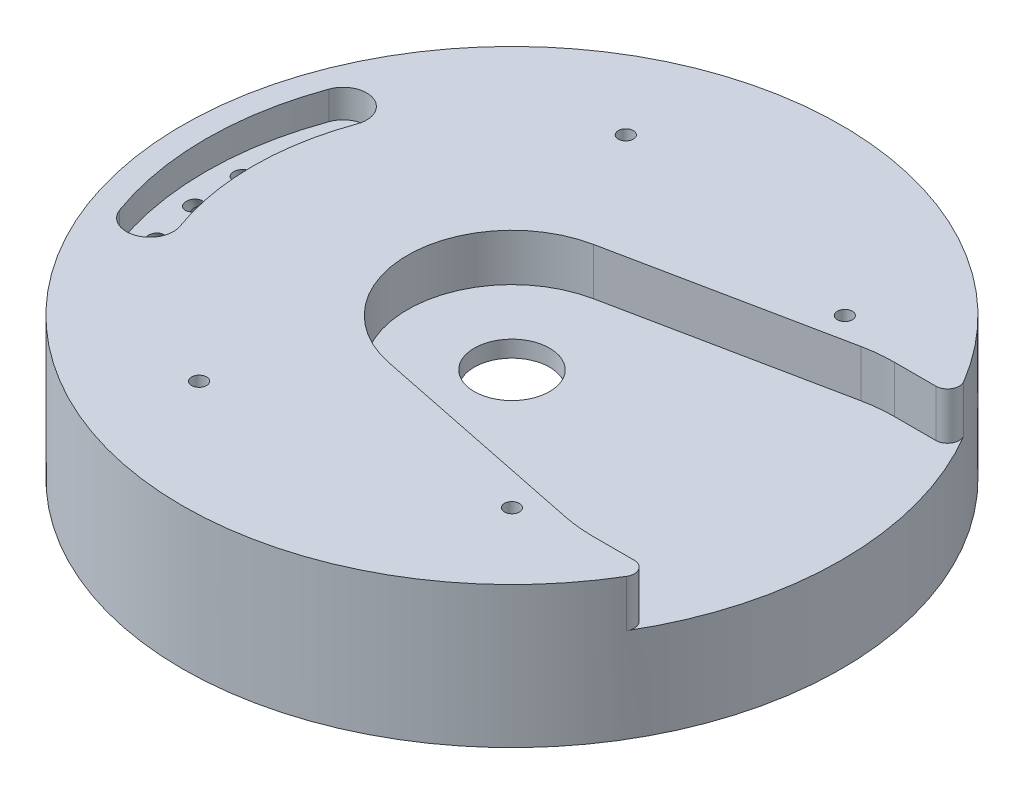
from build123d import *

# Parameters (mm, degrees)
SKETCH1_R                       = 10.16
GEAR_SLOT_DEPTH                 = 12.7
CIRPATTERN1_COUNT               = 2
CIRPATTERN1_ANGLE               = 10
CIRPATTERN1_THE_OTHER_WAY_COUNT = 2
CIRPATTERN1_THE_OTHER_WAY_ANGLE = 10
GAS_MANIFOLD_DEPTH              = 7.62
FILLET1_R                       = 3.175
TAP_DRILL_FOR_10_32_TAP1_D      = 4.0386
TAP_DRILL_FOR_10_32_TAP1_DEPTH  = 17.836682152
TAP_DRILL_FOR_10_32_TAP1_TIP    = 1.213317848


with BuildPart() as part:
    # Sketch9 → Revolve1 (revolve)
    with BuildSketch(Plane.XY, mode=Mode.PRIVATE) as revolve1_sk:
        Polygon((-10.16, 10.16), (-10.16, 27.305), (-88.9, 27.305), (-88.9, -10.795), (-80.645, -10.795), (-80.645, 10.795), (-69.85, 10.795), (-69.85, 5.08), (-58.42, 5.08), (-58.42, 6.35), (-45.72, 6.35), (-45.72, 7.62), (-33.02, 7.62), (-33.02, 10.16), align=None)
    revolve(revolve1_sk.sketch.rotate(Axis((0, 18.1216542, 0), (0, -1, 0)), 270), axis=Axis((0, 18.1216542, 0), (0, -1, 0)))

    # Sketch1 → Gear Slot (cut)
    with BuildSketch(Plane(origin=(0, 27.305, 0), x_dir=(1, 0, 0), z_dir=(0, 1, 0))):
        with BuildLine():
            Line((62.5, -40.675), (79.049063087, -40.675))
            ThreePointArc((79.049063087, -40.675), (88.9, 0), (79.049063087, 40.675))
            Line((79.049063087, 40.675), (62.5, 40.675))
            ThreePointArc((62.5, 40.675), (58.41179797, 40.469028023), (54.365, 39.853198115))
            Line((54.365, 39.853198115), (-5.635, 27.605749401))
            ThreePointArc((-5.635, 27.605749401), (-28.175, 0), (-5.635, -27.605749401))
            Line((-5.635, -27.605749401), (54.365, -39.853198115))
            ThreePointArc((54.365, -39.853198115), (58.41179797, -40.469028023), (62.5, -40.675))
        make_face()
        with Locations(Location((0, 0, 0), (0, 0, 270))):
            Circle(SKETCH1_R, mode=Mode.SUBTRACT)
    extrude(amount=-GEAR_SLOT_DEPTH, mode=Mode.SUBTRACT)

    # Sketch5 one side → Orifice (revolve, cut)
    with BuildSketch(Plane(origin=(-76.2, 0, 0), x_dir=(0, 0, -1), z_dir=(1, 0, 0)), mode=Mode.PRIVATE) as orifice_sk:
        Polygon((-10.063777286, 15.998459659), (-7.555019185, 3.092018098), (-2.67011422, 5.474545442), (-10.464353209, 21.455103585), (-12.290702712, 20.564333415), align=None)
    orifice = revolve(orifice_sk.sketch.rotate(Axis((-76.2, 5.474545442, 2.67011422), (0, 0.8987940462991696, 0.43837114678907213)), 180), axis=Axis((-76.2, 5.474545442, 2.67011422), (0, 0.8987940462991696, 0.43837114678907213)), mode=Mode.SUBTRACT)

    # CirPattern1: Orifice ×2 about axis
    cirpattern1_axis = Axis((0, 17.78, 0), (0, -1, 0))
    for i in range(1, CIRPATTERN1_COUNT):
        add(orifice.rotate(cirpattern1_axis, i * CIRPATTERN1_ANGLE / (CIRPATTERN1_COUNT - 1)), mode=Mode.SUBTRACT)

    # CirPattern1 the other way: Orifice ×2 about axis
    cirpattern1_the_other_way_axis = Axis((0, 17.78, 0), (0, 1, 0))
    for i in range(1, CIRPATTERN1_THE_OTHER_WAY_COUNT):
        add(orifice.rotate(cirpattern1_the_other_way_axis, i * CIRPATTERN1_THE_OTHER_WAY_ANGLE / (CIRPATTERN1_THE_OTHER_WAY_COUNT - 1)), mode=Mode.SUBTRACT)

    # Sketch10 → Gas Manifold (cut)
    with BuildSketch(Plane(origin=(0, 27.305, 0), x_dir=(1, 0, 0), z_dir=(0, 1, 0))):
        with BuildLine():
            ThreePointArc((-65.637529562, -23.890107011), (-69.85, 0), (-65.637529562, 23.890107011))
            ThreePointArc((-65.637529562, 23.890107011), (-69.432749794, 32.028983063), (-77.571625846, 28.233762832))
            ThreePointArc((-77.571625846, 28.233762832), (-82.55, 0), (-77.571625846, -28.233762832))
            ThreePointArc((-77.571625846, -28.233762832), (-69.432749794, -32.028983063), (-65.637529562, -23.890107011))
        make_face()
    extrude(amount=-GAS_MANIFOLD_DEPTH, mode=Mode.SUBTRACT)

    # Fillet1
    fillet1_edges = [part.edges().sort_by_distance(p)[0] for p in [
        (79.049063087, 20.955, -40.675),
        (79.049063087, 20.955, 40.675),
    ]]
    fillet(fillet1_edges, radius=FILLET1_R)

    # Tap Drill for #10-32 Tap1
    with Locations(Plane(origin=(44.901280605, 27.305, -44.901280605), x_dir=(0, 0, 1), z_dir=(0, 1, 0))):
        with Locations((0, 0), (-12.649263872, -71.737540226), (102.451825082, -71.737540226), (89.80256121, 0)):
            Hole(TAP_DRILL_FOR_10_32_TAP1_D / 2, depth=TAP_DRILL_FOR_10_32_TAP1_DEPTH)
            with Locations((0, 0, -(TAP_DRILL_FOR_10_32_TAP1_DEPTH + TAP_DRILL_FOR_10_32_TAP1_TIP / 2))):  # 118° drill point
                Cone(0, TAP_DRILL_FOR_10_32_TAP1_D / 2, TAP_DRILL_FOR_10_32_TAP1_TIP, mode=Mode.SUBTRACT)


solid = part.part
